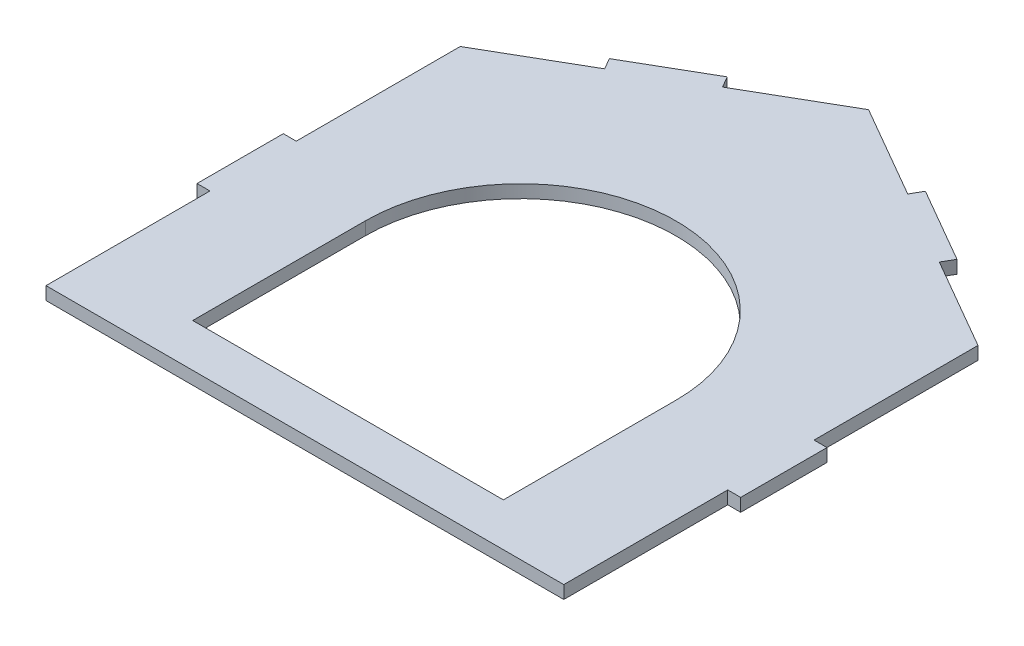
from build123d import *

# Parameters (mm, degrees)
BOSS_EXTRUDE1_DEPTH = 15
CUT_EXTRUDE2_REACH  = 17


with BuildPart() as part:
    # Sketch1 → Boss-Extrude1 (new body)
    with BuildSketch(Plane(origin=(0, 0, 0), x_dir=(1, 0, 0), z_dir=(0, 1, 0))):
        Polygon((-300, -240), (300, -240), (300, -50), (315, -50), (315, 50), (300, 50), (300, 240), (193.911888036, 301.25), (201.411888036, 314.240381057), (114.809347658, 364.240381057), (107.309347658, 351.25), (0, 413.205080757), (-107.309347658, 351.25), (-114.809347658, 364.240381057), (-201.411888036, 314.240381057), (-193.911888036, 301.25), (-300, 240), (-300, 50), (-315, 50), (-315, -50), (-300, -50), align=None)
    extrude(amount=BOSS_EXTRUDE1_DEPTH)

    # Sketch2 → Cut-Extrude2 (cut, up to next)
    with BuildSketch(Plane(origin=(0, 15, 0), x_dir=(1, 0, 0), z_dir=(0, 1, 0)), mode=Mode.PRIVATE) as cut_extrude2_sk1:
        with BuildLine():
            Line((-180, -190), (180, -190))
            Line((180, -190), (180, 10))
            ThreePointArc((180, 10), (0, 190), (-180, 10))
            Line((-180, 10), (-180, -190))
        make_face()
    cut_extrude2_tool1 = extrude(cut_extrude2_sk1.sketch, amount=-CUT_EXTRUDE2_REACH, mode=Mode.PRIVATE) & part.part
    add(cut_extrude2_tool1.solids().sort_by_distance((0, 15, 16.950098))[0], mode=Mode.SUBTRACT)


solid = part.part
